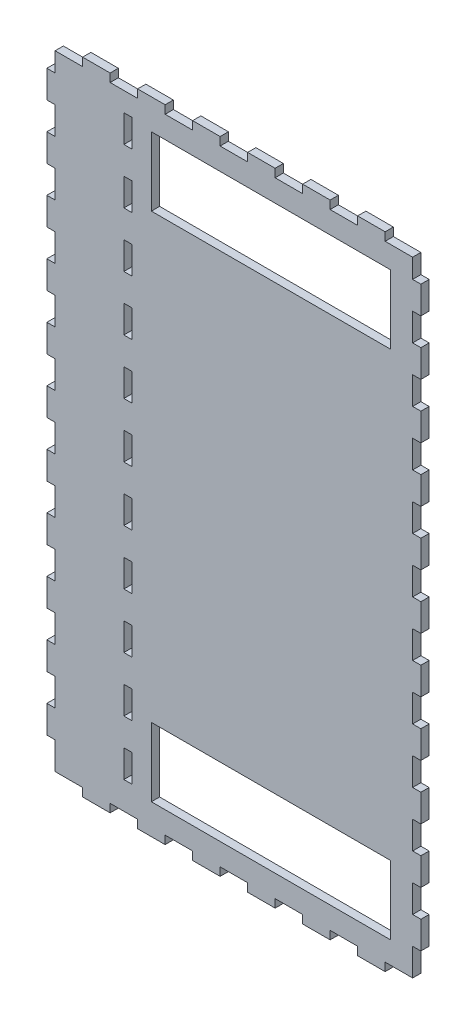
from build123d import *

# Parameters (mm, degrees)
SKETCH1_W           = 130
SKETCH1_H           = 227
SKETCH1_W_2         = 87
SKETCH1_H_2         = 25
BOSS_EXTRUDE1_DEPTH = 3
SKETCH2_W           = 10
SKETCH2_H           = 3
BOSS_EXTRUDE2_DEPTH = 3
LPATTERN1_COUNT     = 6
LPATTERN1_PITCH     = 20
SKETCH3_W           = 10
SKETCH3_H           = 3
BOSS_EXTRUDE3_DEPTH = 3
LPATTERN2_COUNT     = 6
LPATTERN2_PITCH     = 20
SKETCH4_W           = 3
SKETCH4_H           = 10
BOSS_EXTRUDE4_DEPTH = 3
LPATTERN3_COUNT     = 11
LPATTERN3_PITCH     = 20
SKETCH5_W           = 3
SKETCH5_H           = 10
BOSS_EXTRUDE5_DEPTH = 3
LPATTERN4_COUNT     = 11
LPATTERN4_PITCH     = 20
SKETCH6_W           = 3
SKETCH6_H           = 10
CUT_EXTRUDE1_DEPTH  = 3
LPATTERN5_COUNT     = 11
LPATTERN5_PITCH     = 20


with BuildPart() as part:
    # Sketch1 → Boss-Extrude1 (new body)
    with BuildSketch(Plane.XY):
        with Locations((65, 113.5)):
            Rectangle(SKETCH1_W, SKETCH1_H)
        with Locations((78.5, 20.5)):
            Rectangle(SKETCH1_W_2, SKETCH1_H_2, mode=Mode.SUBTRACT)
        with Locations((78.5, 206.5)):
            Rectangle(SKETCH1_W_2, SKETCH1_H_2, mode=Mode.SUBTRACT)
    extrude(amount=BOSS_EXTRUDE1_DEPTH)

    # Sketch2 → Boss-Extrude2 (add)
    with BuildSketch(Plane.XZ):
        with Locations((15, 1.5)):
            Rectangle(SKETCH2_W, SKETCH2_H)
    boss_extrude2 = extrude(amount=BOSS_EXTRUDE2_DEPTH)

    # LPattern1: Boss-Extrude2 ×6
    with Locations(*[(i * LPATTERN1_PITCH, 0, 0) for i in range(1, LPATTERN1_COUNT)]):
        add(boss_extrude2)

    # Sketch3 → Boss-Extrude3 (add)
    with BuildSketch(Plane(origin=(0, 227, 0), x_dir=(1, 0, 0), z_dir=(0, 1, 0))):
        with Locations((15, -1.5)):
            Rectangle(SKETCH3_W, SKETCH3_H)
    boss_extrude3 = extrude(amount=BOSS_EXTRUDE3_DEPTH)

    # LPattern2: Boss-Extrude3 ×6
    with Locations(*[(i * LPATTERN2_PITCH, 0, 0) for i in range(1, LPATTERN2_COUNT)]):
        add(boss_extrude3)

    # Sketch4 → Boss-Extrude4 (add)
    with BuildSketch(Plane(origin=(130, 0, 0), x_dir=(0, 0, -1), z_dir=(1, 0, 0))):
        with Locations((-1.5, 15)):
            Rectangle(SKETCH4_W, SKETCH4_H)
    boss_extrude4 = extrude(amount=BOSS_EXTRUDE4_DEPTH)

    # LPattern3: Boss-Extrude4 ×11
    with Locations(*[(0, i * LPATTERN3_PITCH, 0) for i in range(1, LPATTERN3_COUNT)]):
        add(boss_extrude4)

    # Sketch5 → Boss-Extrude5 (add)
    with BuildSketch(Plane.ZY):
        with Locations((1.5, 15)):
            Rectangle(SKETCH5_W, SKETCH5_H)
    boss_extrude5 = extrude(amount=BOSS_EXTRUDE5_DEPTH)

    # LPattern4: Boss-Extrude5 ×11
    with Locations(*[(0, i * LPATTERN4_PITCH, 0) for i in range(1, LPATTERN4_COUNT)]):
        add(boss_extrude5)

    # Sketch6 → Cut-Extrude1 (cut)
    with BuildSketch(Plane.XY.offset(3)):
        with Locations((26.5, 15)):
            Rectangle(SKETCH6_W, SKETCH6_H)
    cut_extrude1 = extrude(amount=-CUT_EXTRUDE1_DEPTH, mode=Mode.SUBTRACT)

    # LPattern5: Cut-Extrude1 ×11
    with Locations(*[(0, i * LPATTERN5_PITCH, 0) for i in range(1, LPATTERN5_COUNT)]):
        add(cut_extrude1, mode=Mode.SUBTRACT)


solid = part.part
